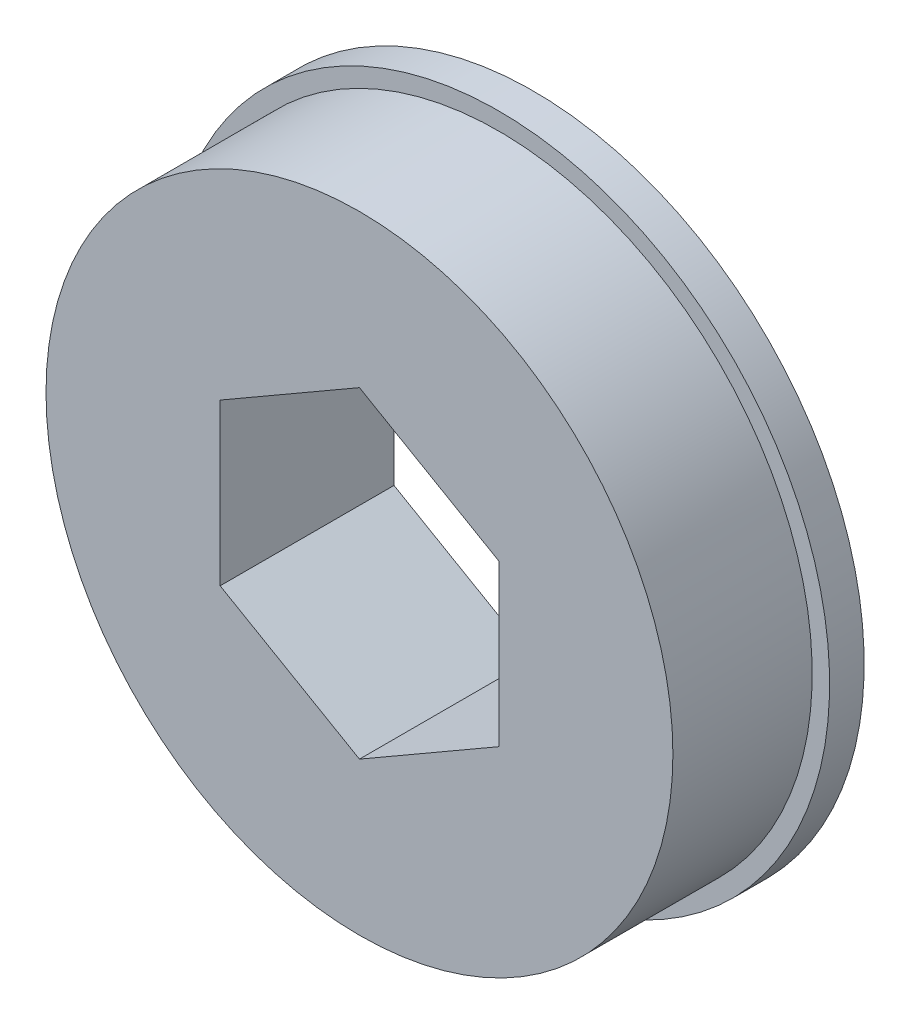
from build123d import *

# Parameters (mm, degrees)
SKETCH1_R           = 14.2875
BOSS_EXTRUDE1_DEPTH = 6.35
SKETCH2_R           = 15.08125
BOSS_EXTRUDE2_DEPTH = 1.5748


with BuildPart() as part:
    # Sketch1 → Boss-Extrude1 (new body)
    with BuildSketch(Plane.XY):
        Circle(SKETCH1_R)
        Polygon((6.35, 3.666174209), (0, 7.332348419), (-6.35, 3.666174209), (-6.35, -3.666174209), (0, -7.332348419), (6.35, -3.666174209), align=None, mode=Mode.SUBTRACT)
    extrude(amount=BOSS_EXTRUDE1_DEPTH)

    # Sketch2 → Boss-Extrude2 (add)
    with BuildSketch(Plane(origin=(0, 0, 0), x_dir=(-1, 0, 0), z_dir=(0, 0, -1))):
        Circle(SKETCH2_R)
        Polygon((0, 7.332348419), (-6.35, 3.666174209), (-6.35, -3.666174209), (0, -7.332348419), (6.35, -3.666174209), (6.35, 3.666174209), align=None, mode=Mode.SUBTRACT)
    extrude(amount=BOSS_EXTRUDE2_DEPTH)


solid = part.part
